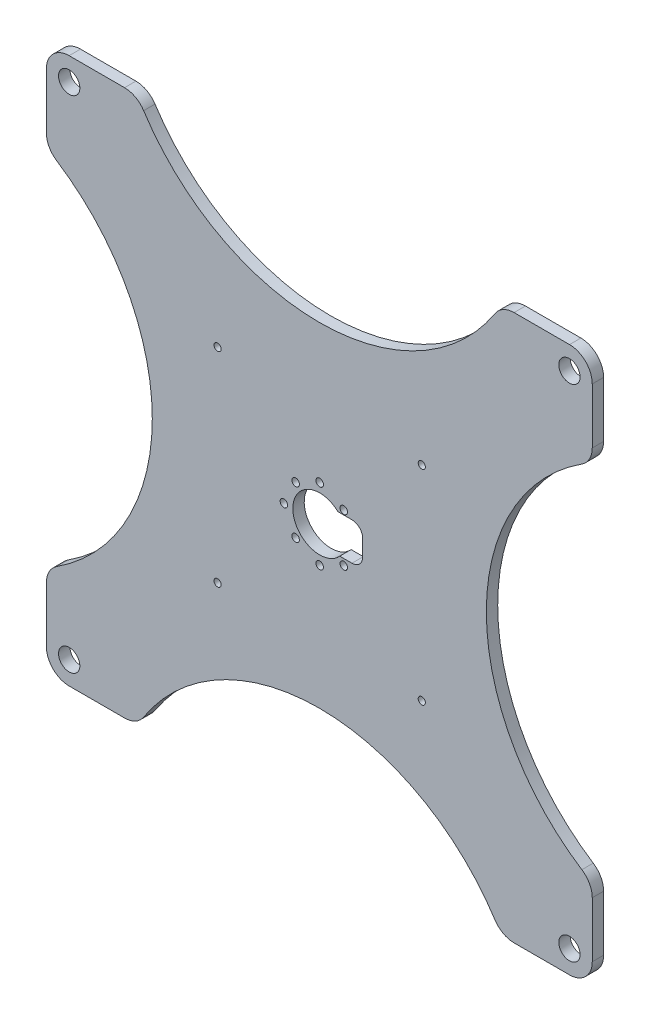
from build123d import *

# Parameters (mm, degrees)
SKETCH3_W             = 152.4
SKETCH3_H             = 152.4
BOSS_EXTRUDE3_DEPTH   = 3.175
SKETCH13_R            = 7.5
CUT_EXTRUDE5_DEPTH    = 4.175
SKETCH15_R            = 1
CUT_EXTRUDE6_DEPTH    = 4.175
SKETCH17_W            = 12
SKETCH17_H            = 10.5
CUT_EXTRUDE7_DEPTH    = 4.175
FILLET1_R             = 3
SKETCH19_R            = 1.05
CUT_EXTRUDE8_DEPTH    = 4.175
SKETCH20_R            = 2.9718
BOLT_HOLES_DEPTH      = 1
BOLT_HOLES_DEPTH_BACK = 4.175
CUT_EXTRUDE12_DEPTH   = 3.175
FILLET2_R             = 6.35
MIRROR5_COPY_1_DEPTH  = 3.175
FILLET3_R             = 6.35
FILLET4_R             = 6.35


with BuildPart() as part:
    # Sketch3 → Boss-Extrude3 (new body)
    with BuildSketch(Plane.XY):
        Rectangle(SKETCH3_W, SKETCH3_H)
    extrude(amount=BOSS_EXTRUDE3_DEPTH)

    # Sketch13 → Cut-Extrude5 (cut, through all)
    with BuildSketch(Plane(origin=(0.106889783, -2.03090588, 3.175), x_dir=(1, 0, 0), z_dir=(0, 0, 1))):
        Circle(SKETCH13_R)
    extrude(amount=-CUT_EXTRUDE5_DEPTH, mode=Mode.SUBTRACT)

    # Sketch15 → Cut-Extrude6 (cut, through all)
    with BuildSketch(Plane(origin=(0.106889783, -2.03090588, 3.175), x_dir=(1, 0, 0), z_dir=(0, 0, 1))):
        with Locations((-28.5, -28.5)):
            Circle(SKETCH15_R)
        with Locations((-28.5, 28.5)):
            Circle(SKETCH15_R)
        with Locations((28.5, -28.5)):
            Circle(SKETCH15_R)
        with Locations((28.5, 28.5)):
            Circle(SKETCH15_R)
    extrude(amount=-CUT_EXTRUDE6_DEPTH, mode=Mode.SUBTRACT)

    # Sketch17 → Cut-Extrude7 (cut, through all)
    with BuildSketch(Plane(origin=(0.106889783, -2.03090588, 3.175), x_dir=(1, 0, 0), z_dir=(0, 0, 1))):
        with Locations((6, 0.25)):
            Rectangle(SKETCH17_W, SKETCH17_H)
    extrude(amount=-CUT_EXTRUDE7_DEPTH, mode=Mode.SUBTRACT)

    # Fillet1
    fillet1_edges = [part.edges().sort_by_distance(p)[0] for p in [
        (12.106889783, -7.03090588, 1.5875),
        (12.106889783, 3.46909412, 1.5875),
    ]]
    fillet(fillet1_edges, radius=FILLET1_R)

    # Sketch19 → Cut-Extrude8 (cut, through all)
    with BuildSketch(Plane(origin=(0.106889783, -2.03090588, 3.175), x_dir=(1, 0, 0), z_dir=(0, 0, 1))):
        with Locations((6.72, 6.72)):
            Circle(SKETCH19_R)
        with Locations((-6.72, 6.72)):
            Circle(SKETCH19_R)
        with Locations((-6.72, -6.72)):
            Circle(SKETCH19_R)
        with Locations((6.72, -6.72)):
            Circle(SKETCH19_R)
        with Locations((0, 10)):
            Circle(SKETCH19_R)
        with Locations((-10, 0)):
            Circle(SKETCH19_R)
        with Locations((0, -10)):
            Circle(SKETCH19_R)
    extrude(amount=-CUT_EXTRUDE8_DEPTH, mode=Mode.SUBTRACT)

    # Sketch20 → Bolt Holes (cut, two sides)
    with BuildSketch(Plane.XY.offset(3.175)) as bolt_holes_sk:
        with Locations((-69.83, 69.83)):
            Circle(SKETCH20_R)
        with Locations((69.83, 69.83)):
            Circle(SKETCH20_R)
        with Locations((69.83, -69.83)):
            Circle(SKETCH20_R)
        with Locations((-69.83, -69.83)):
            Circle(SKETCH20_R)
    extrude(amount=BOLT_HOLES_DEPTH, mode=Mode.SUBTRACT)
    extrude(bolt_holes_sk.sketch, amount=-BOLT_HOLES_DEPTH_BACK, mode=Mode.SUBTRACT)

    # Sketch25 → Cut-Extrude12 (cut)
    with BuildSketch(Plane.XY.offset(3.175)):
        with BuildLine():
            Line((-76.2, 50.8), (-76.2, -50.8))
            ThreePointArc((-76.2, -50.8), (-46.628854397, 0), (-76.2, 50.8))
        make_face()
    cut_extrude12 = extrude(amount=-CUT_EXTRUDE12_DEPTH, mode=Mode.SUBTRACT)

    # Fillet2
    fillet2_edges = [part.edges().sort_by_distance(p)[0] for p in [
        (-76.2, -50.8, 1.5875),
        (-76.2, 50.8, 1.5875),
        (-76.2, -76.2, 1.5875),
        (-76.2, 76.2, 1.5875),
    ]]
    fillet(fillet2_edges, radius=FILLET2_R)

    # Mirror4: Cut-Extrude12 across plane
    add(cut_extrude12.mirror(Plane(origin=(0, 0, 0), x_dir=(0, 0, 1), z_dir=(0.707106781, -0.707106781, 0))), mode=Mode.SUBTRACT)

    # Mirror5: Cut-Extrude12 across plane
    add(cut_extrude12.mirror(Plane(origin=(0, 0, 0), x_dir=(0, 0, 1), z_dir=(-0.707106781, -0.707106781, 0))), mode=Mode.SUBTRACT)

    # Mirror5 copy 1 sketch → Mirror5 copy 1 (cut)
    with BuildSketch(Plane(origin=(0, 0, 3.175), x_dir=(-1, 0, 0), z_dir=(0, 0, 1))):
        with BuildLine():
            Line((-76.2, 50.8), (-76.2, -50.8))
            ThreePointArc((-76.2, -50.8), (-46.628854397, 0), (-76.2, 50.8))
        make_face()
    extrude(amount=-MIRROR5_COPY_1_DEPTH, mode=Mode.SUBTRACT)

    # Fillet3
    fillet3_edges = [part.edges().sort_by_distance(p)[0] for p in [
        (-50.8, -76.2, 1.5875),
        (50.8, -76.2, 1.5875),
        (76.2, 50.8, 1.5875),
        (76.2, -50.8, 1.5875),
        (76.2, -76.2, 1.5875),
        (76.2, 76.2, 1.5875),
    ]]
    fillet(fillet3_edges, radius=FILLET3_R)

    # Fillet4
    fillet4_edges = [part.edges().sort_by_distance(p)[0] for p in [
        (50.8, 76.2, 1.5875),
        (-50.8, 76.2, 1.5875),
    ]]
    fillet(fillet4_edges, radius=FILLET4_R)


solid = part.part
